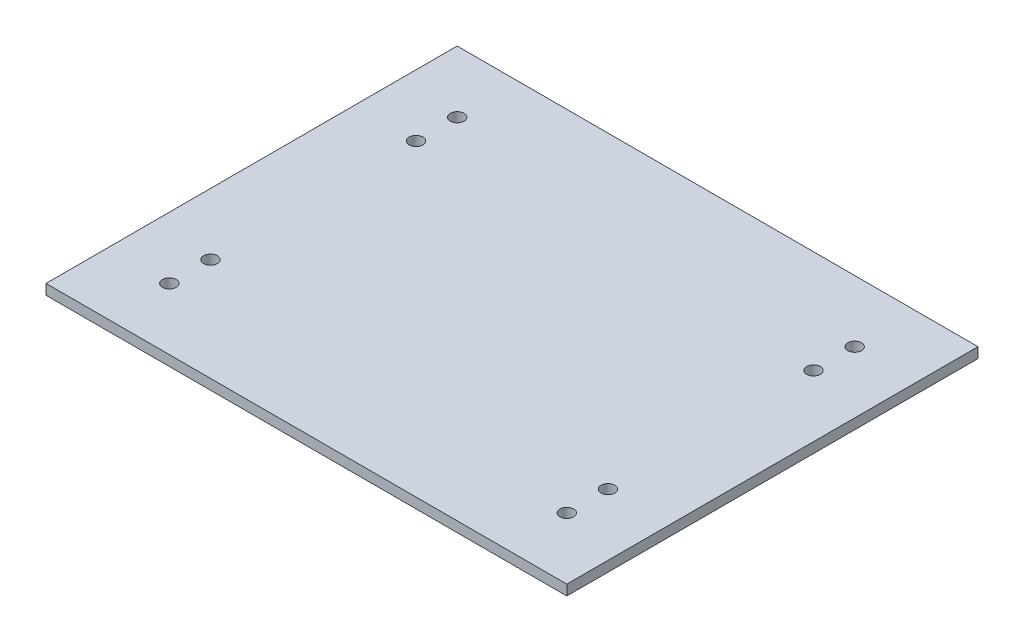
from build123d import *

# Parameters (mm, degrees)
SKETCH1_W           = 152
SKETCH1_H           = 120
BOSS_EXTRUDE1_DEPTH = 3
SKETCH2_R           = 2
CUT_EXTRUDE1_DEPTH  = 4
SKETCH5_R           = 2
CUT_EXTRUDE3_DEPTH  = 4
SKETCH6_R           = 2
CUT_EXTRUDE4_DEPTH  = 4


with BuildPart() as part:
    # Sketch1 → Boss-Extrude1 (new body)
    with BuildSketch(Plane(origin=(0, 0, 0), x_dir=(1, 0, 0), z_dir=(0, 1, 0))):
        with Locations((28.968311827, 11.899409823)):
            Rectangle(SKETCH1_W, SKETCH1_H)
    extrude(amount=BOSS_EXTRUDE1_DEPTH)

    # Sketch2 → Cut-Extrude1 (cut, through all)
    with BuildSketch(Plane(origin=(0, 3, 0), x_dir=(-1, 0, 0), z_dir=(0, 1, 0))):
        with Locations((-86.968311827, 30.100590177)):
            Circle(SKETCH2_R)
    extrude(amount=-CUT_EXTRUDE1_DEPTH, mode=Mode.SUBTRACT)

    # Sketch5 → Cut-Extrude3 (cut, through all)
    with BuildSketch(Plane(origin=(0, 3, 0), x_dir=(-1, 0, 0), z_dir=(0, 1, 0))):
        with Locations((-86.968311827, 18.100590177)):
            Circle(SKETCH5_R)
    extrude(amount=-CUT_EXTRUDE3_DEPTH, mode=Mode.SUBTRACT)

    # Sketch6 → Cut-Extrude4 (cut, through all)
    with BuildSketch(Plane(origin=(0, 3, 0), x_dir=(-1, 0, 0), z_dir=(0, 1, 0))):
        with Locations((-86.968311827, -41.899409823)):
            Circle(SKETCH6_R)
        with Locations((29.031688173, -53.899409823)):
            Circle(SKETCH6_R)
        with Locations((-86.968311827, -53.899409823)):
            Circle(SKETCH6_R)
        with Locations((29.031688173, -41.899409823)):
            Circle(SKETCH6_R)
        with Locations((29.031688173, 18.100590177)):
            Circle(SKETCH6_R)
        with Locations((29.031688173, 30.100590177)):
            Circle(SKETCH6_R)
    extrude(amount=-CUT_EXTRUDE4_DEPTH, mode=Mode.SUBTRACT)


solid = part.part
